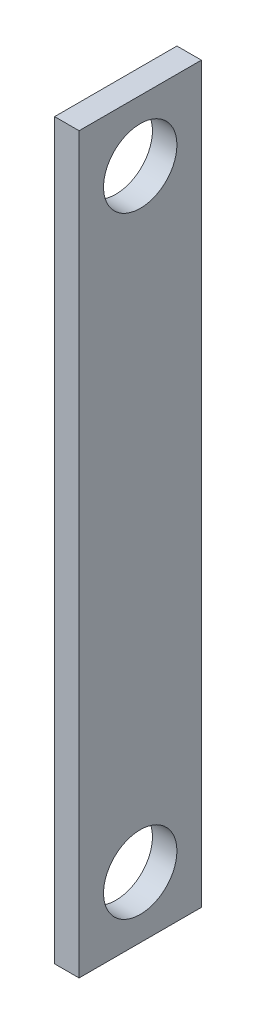
from build123d import *

# Parameters (mm, degrees)
SKETCH1_W           = 10
SKETCH1_H           = 60
BOSS_EXTRUDE1_DEPTH = 2
SKETCH2_R           = 3
CUT_EXTRUDE1_DEPTH  = 2


with BuildPart() as part:
    # Sketch1 → Boss-Extrude1 (new body)
    with BuildSketch(Plane(origin=(0, 0, 0), x_dir=(0, 0, -1), z_dir=(1, 0, 0))):
        Rectangle(SKETCH1_W, SKETCH1_H)
    extrude(amount=BOSS_EXTRUDE1_DEPTH)

    # Sketch2 → Cut-Extrude1 (cut)
    with BuildSketch(Plane(origin=(2, 0, 0), x_dir=(0, 0, -1), z_dir=(1, 0, 0))):
        with Locations((0, -25)):
            Circle(SKETCH2_R)
        with Locations((0, 25)):
            Circle(SKETCH2_R)
    extrude(amount=-CUT_EXTRUDE1_DEPTH, mode=Mode.SUBTRACT)


solid = part.part
